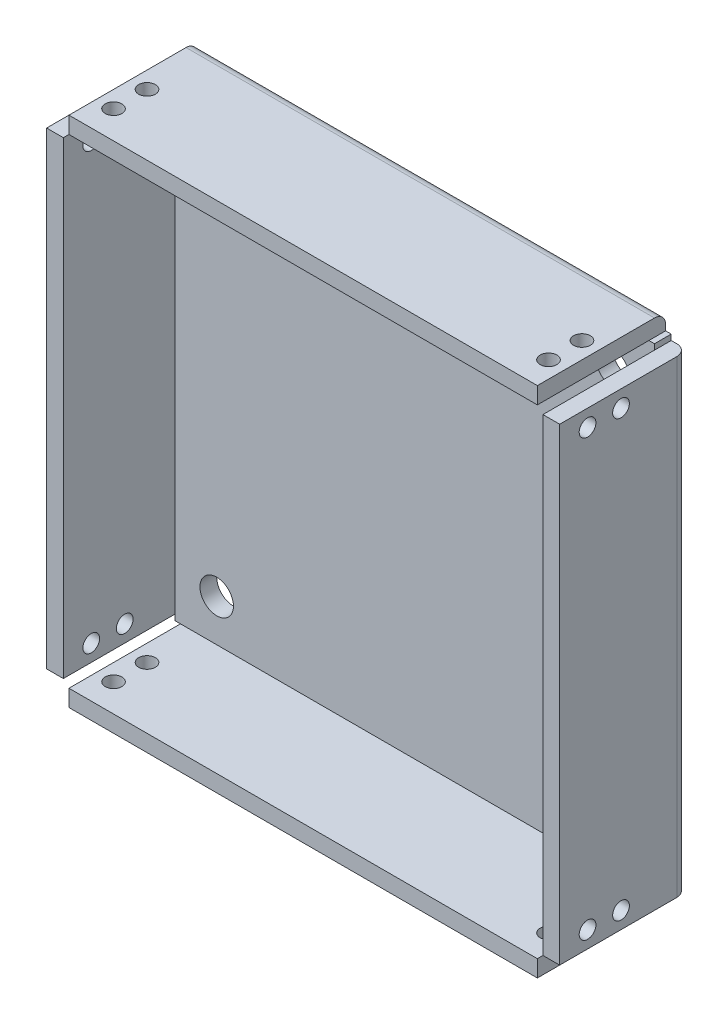
from build123d import *

# Parameters (mm, degrees)
SKETCH1_R           = 3
BOSS_EXTRUDE1_DEPTH = 3
SKETCH1_4_W         = 3
SKETCH1_4_H         = 84
SKETCH1_4_W_2       = 84
SKETCH1_4_H_2       = 3
BOSS_EXTRUDE3_DEPTH = 23
FILLET1_R           = 2
CUT_EXTRUDE1_REACH  = 118.877
SKETCH2_R           = 1.5
CUT_EXTRUDE2_REACH  = 117.936
SKETCH3_R           = 1.5
CUT_EXTRUDE3_REACH  = 118.877
SKETCH4_R           = 1.5
CUT_EXTRUDE4_REACH  = 117.936
SKETCH5_R           = 1.5


with BuildPart() as part:
    # Sketch1 → Boss-Extrude1 (new body)
    with BuildSketch(Plane.XY):
        Polygon((-62.693877551, 65.317784257), (-63.693877551, 65.317784257), (-63.693877551, 64.317784257), (-63.693877551, -19.682215743), (-63.693877551, -20.682215743), (-62.693877551, -20.682215743), (21.306122449, -20.682215743), (22.306122449, -20.682215743), (22.306122449, -19.682215743), (22.306122449, 64.317784257), (22.306122449, 65.317784257), (21.306122449, 65.317784257), align=None)
        with Locations((-56.193877551, -13.182215743)):
            Circle(SKETCH1_R, mode=Mode.SUBTRACT)
        with Locations((14.806122449, -13.182215743)):
            Circle(SKETCH1_R, mode=Mode.SUBTRACT)
        with Locations((-56.193877551, 57.817784257)):
            Circle(SKETCH1_R, mode=Mode.SUBTRACT)
        with Locations((14.806122449, 57.817784257)):
            Circle(SKETCH1_R, mode=Mode.SUBTRACT)
    extrude(amount=BOSS_EXTRUDE1_DEPTH)

    # Sketch1_4 → Boss-Extrude3 (add)
    with BuildSketch(Plane.XY):
        with Locations((-65.193877551, 22.317784257)):
            Rectangle(SKETCH1_4_W, SKETCH1_4_H)
        with Locations((-20.693877551, 66.817784257)):
            Rectangle(SKETCH1_4_W_2, SKETCH1_4_H_2)
        with Locations((-20.693877551, -22.182215743)):
            Rectangle(SKETCH1_4_W_2, SKETCH1_4_H_2)
        with Locations((23.806122449, 22.317784257)):
            Rectangle(SKETCH1_4_W, SKETCH1_4_H)
    extrude(amount=BOSS_EXTRUDE3_DEPTH)

    # Fillet1
    fillet1_edges = [part.edges().sort_by_distance(p)[0] for p in [
        (-20.693877551, -23.682215743, 0),
        (-66.693877551, 22.317784257, 0),
        (-20.693877551, 68.317784257, 0),
        (25.306122449, 22.317784257, 0),
    ]]
    fillet(fillet1_edges, radius=FILLET1_R)

    # Sketch2 → Cut-Extrude1 (cut, up to next)
    with BuildSketch(Plane.ZY.offset(66.693877551), mode=Mode.PRIVATE) as cut_extrude1_sk1:
        with Locations((12, -16.682215743)):
            Circle(SKETCH2_R)
    cut_extrude1_tool1 = extrude(cut_extrude1_sk1.sketch, amount=-CUT_EXTRUDE1_REACH, mode=Mode.PRIVATE) & part.part
    # Sketch2 → Cut-Extrude1 (cut, up to next)
    with BuildSketch(Plane.ZY.offset(66.693877551), mode=Mode.PRIVATE) as cut_extrude1_sk2:
        with Locations((18, -16.682215743)):
            Circle(SKETCH2_R)
    cut_extrude1_tool2 = extrude(cut_extrude1_sk2.sketch, amount=-CUT_EXTRUDE1_REACH, mode=Mode.PRIVATE) & part.part
    # Sketch2 → Cut-Extrude1 (cut, up to next)
    with BuildSketch(Plane.ZY.offset(66.693877551), mode=Mode.PRIVATE) as cut_extrude1_sk3:
        with Locations((12, 61.317784257)):
            Circle(SKETCH2_R)
    cut_extrude1_tool3 = extrude(cut_extrude1_sk3.sketch, amount=-CUT_EXTRUDE1_REACH, mode=Mode.PRIVATE) & part.part
    # Sketch2 → Cut-Extrude1 (cut, up to next)
    with BuildSketch(Plane.ZY.offset(66.693877551), mode=Mode.PRIVATE) as cut_extrude1_sk4:
        with Locations((18, 61.317784257)):
            Circle(SKETCH2_R)
    cut_extrude1_tool4 = extrude(cut_extrude1_sk4.sketch, amount=-CUT_EXTRUDE1_REACH, mode=Mode.PRIVATE) & part.part
    add(cut_extrude1_tool1.solids().sort_by_distance((-66.693878, -16.682216, 12))[0], mode=Mode.SUBTRACT)
    add(cut_extrude1_tool2.solids().sort_by_distance((-66.693878, -16.682216, 18))[0], mode=Mode.SUBTRACT)
    add(cut_extrude1_tool3.solids().sort_by_distance((-66.693878, 61.317784, 12))[0], mode=Mode.SUBTRACT)
    add(cut_extrude1_tool4.solids().sort_by_distance((-66.693878, 61.317784, 18))[0], mode=Mode.SUBTRACT)

    # Sketch3 → Cut-Extrude2 (cut, up to next)
    with BuildSketch(Plane.XZ.offset(23.682215743), mode=Mode.PRIVATE) as cut_extrude2_sk1:
        with Locations((18.306122449, 12)):
            Circle(SKETCH3_R)
    cut_extrude2_tool1 = extrude(cut_extrude2_sk1.sketch, amount=-CUT_EXTRUDE2_REACH, mode=Mode.PRIVATE) & part.part
    # Sketch3 → Cut-Extrude2 (cut, up to next)
    with BuildSketch(Plane.XZ.offset(23.682215743), mode=Mode.PRIVATE) as cut_extrude2_sk2:
        with Locations((18.306122449, 18)):
            Circle(SKETCH3_R)
    cut_extrude2_tool2 = extrude(cut_extrude2_sk2.sketch, amount=-CUT_EXTRUDE2_REACH, mode=Mode.PRIVATE) & part.part
    # Sketch3 → Cut-Extrude2 (cut, up to next)
    with BuildSketch(Plane.XZ.offset(23.682215743), mode=Mode.PRIVATE) as cut_extrude2_sk3:
        with Locations((-59.693877551, 12)):
            Circle(SKETCH3_R)
    cut_extrude2_tool3 = extrude(cut_extrude2_sk3.sketch, amount=-CUT_EXTRUDE2_REACH, mode=Mode.PRIVATE) & part.part
    # Sketch3 → Cut-Extrude2 (cut, up to next)
    with BuildSketch(Plane.XZ.offset(23.682215743), mode=Mode.PRIVATE) as cut_extrude2_sk4:
        with Locations((-59.693877551, 18)):
            Circle(SKETCH3_R)
    cut_extrude2_tool4 = extrude(cut_extrude2_sk4.sketch, amount=-CUT_EXTRUDE2_REACH, mode=Mode.PRIVATE) & part.part
    add(cut_extrude2_tool1.solids().sort_by_distance((18.306122, -23.682216, 12))[0], mode=Mode.SUBTRACT)
    add(cut_extrude2_tool2.solids().sort_by_distance((18.306122, -23.682216, 18))[0], mode=Mode.SUBTRACT)
    add(cut_extrude2_tool3.solids().sort_by_distance((-59.693878, -23.682216, 12))[0], mode=Mode.SUBTRACT)
    add(cut_extrude2_tool4.solids().sort_by_distance((-59.693878, -23.682216, 18))[0], mode=Mode.SUBTRACT)

    # Sketch4 → Cut-Extrude3 (cut, up to next)
    with BuildSketch(Plane(origin=(25.306122449, 0, 0), x_dir=(0, 0, -1), z_dir=(1, 0, 0)), mode=Mode.PRIVATE) as cut_extrude3_sk1:
        with Locations((-12, 61.317784257)):
            Circle(SKETCH4_R)
    cut_extrude3_tool1 = extrude(cut_extrude3_sk1.sketch, amount=-CUT_EXTRUDE3_REACH, mode=Mode.PRIVATE) & part.part
    # Sketch4 → Cut-Extrude3 (cut, up to next)
    with BuildSketch(Plane(origin=(25.306122449, 0, 0), x_dir=(0, 0, -1), z_dir=(1, 0, 0)), mode=Mode.PRIVATE) as cut_extrude3_sk2:
        with Locations((-18, 61.317784257)):
            Circle(SKETCH4_R)
    cut_extrude3_tool2 = extrude(cut_extrude3_sk2.sketch, amount=-CUT_EXTRUDE3_REACH, mode=Mode.PRIVATE) & part.part
    # Sketch4 → Cut-Extrude3 (cut, up to next)
    with BuildSketch(Plane(origin=(25.306122449, 0, 0), x_dir=(0, 0, -1), z_dir=(1, 0, 0)), mode=Mode.PRIVATE) as cut_extrude3_sk3:
        with Locations((-12, -16.682215743)):
            Circle(SKETCH4_R)
    cut_extrude3_tool3 = extrude(cut_extrude3_sk3.sketch, amount=-CUT_EXTRUDE3_REACH, mode=Mode.PRIVATE) & part.part
    # Sketch4 → Cut-Extrude3 (cut, up to next)
    with BuildSketch(Plane(origin=(25.306122449, 0, 0), x_dir=(0, 0, -1), z_dir=(1, 0, 0)), mode=Mode.PRIVATE) as cut_extrude3_sk4:
        with Locations((-18, -16.682215743)):
            Circle(SKETCH4_R)
    cut_extrude3_tool4 = extrude(cut_extrude3_sk4.sketch, amount=-CUT_EXTRUDE3_REACH, mode=Mode.PRIVATE) & part.part
    add(cut_extrude3_tool1.solids().sort_by_distance((25.306122, 61.317784, 12))[0], mode=Mode.SUBTRACT)
    add(cut_extrude3_tool2.solids().sort_by_distance((25.306122, 61.317784, 18))[0], mode=Mode.SUBTRACT)
    add(cut_extrude3_tool3.solids().sort_by_distance((25.306122, -16.682216, 12))[0], mode=Mode.SUBTRACT)
    add(cut_extrude3_tool4.solids().sort_by_distance((25.306122, -16.682216, 18))[0], mode=Mode.SUBTRACT)

    # Sketch5 → Cut-Extrude4 (cut, up to next)
    with BuildSketch(Plane(origin=(0, 68.317784257, 0), x_dir=(1, 0, 0), z_dir=(0, 1, 0)), mode=Mode.PRIVATE) as cut_extrude4_sk1:
        with Locations((-59.693877551, -12)):
            Circle(SKETCH5_R)
    cut_extrude4_tool1 = extrude(cut_extrude4_sk1.sketch, amount=-CUT_EXTRUDE4_REACH, mode=Mode.PRIVATE) & part.part
    # Sketch5 → Cut-Extrude4 (cut, up to next)
    with BuildSketch(Plane(origin=(0, 68.317784257, 0), x_dir=(1, 0, 0), z_dir=(0, 1, 0)), mode=Mode.PRIVATE) as cut_extrude4_sk2:
        with Locations((-59.693877551, -18)):
            Circle(SKETCH5_R)
    cut_extrude4_tool2 = extrude(cut_extrude4_sk2.sketch, amount=-CUT_EXTRUDE4_REACH, mode=Mode.PRIVATE) & part.part
    # Sketch5 → Cut-Extrude4 (cut, up to next)
    with BuildSketch(Plane(origin=(0, 68.317784257, 0), x_dir=(1, 0, 0), z_dir=(0, 1, 0)), mode=Mode.PRIVATE) as cut_extrude4_sk3:
        with Locations((18.306122449, -18)):
            Circle(SKETCH5_R)
    cut_extrude4_tool3 = extrude(cut_extrude4_sk3.sketch, amount=-CUT_EXTRUDE4_REACH, mode=Mode.PRIVATE) & part.part
    # Sketch5 → Cut-Extrude4 (cut, up to next)
    with BuildSketch(Plane(origin=(0, 68.317784257, 0), x_dir=(1, 0, 0), z_dir=(0, 1, 0)), mode=Mode.PRIVATE) as cut_extrude4_sk4:
        with Locations((18.306122449, -12)):
            Circle(SKETCH5_R)
    cut_extrude4_tool4 = extrude(cut_extrude4_sk4.sketch, amount=-CUT_EXTRUDE4_REACH, mode=Mode.PRIVATE) & part.part
    add(cut_extrude4_tool1.solids().sort_by_distance((-59.693878, 68.317784, 12))[0], mode=Mode.SUBTRACT)
    add(cut_extrude4_tool2.solids().sort_by_distance((-59.693878, 68.317784, 18))[0], mode=Mode.SUBTRACT)
    add(cut_extrude4_tool3.solids().sort_by_distance((18.306122, 68.317784, 18))[0], mode=Mode.SUBTRACT)
    add(cut_extrude4_tool4.solids().sort_by_distance((18.306122, 68.317784, 12))[0], mode=Mode.SUBTRACT)


solid = part.part
